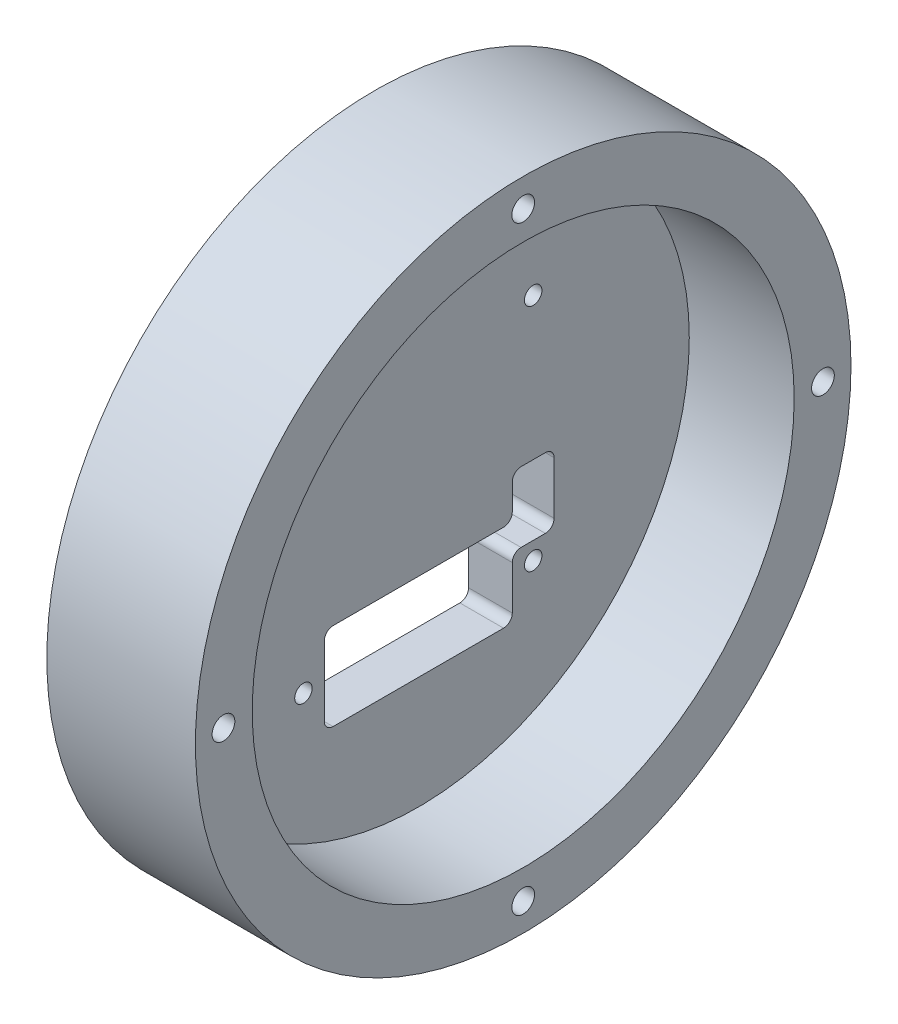
from build123d import *

# Parameters (mm, degrees)
SKETCH1_R               = 37.5
BOSS_EXTRUDE1_DEPTH     = 5
SKETCH3_R               = 1
CUT_EXTRUDE2_DEPTH      = 6
SKETCH4_R               = 37.5
SKETCH4_R_2             = 31
BOSS_EXTRUDE2_DEPTH     = 12
SKETCH2_R               = 1.3
CUT_EXTRUDE1_DEPTH      = 13
CUT_EXTRUDE1_DEPTH_BACK = 6
CUT_EXTRUDE3_DEPTH      = 6


with BuildPart() as part:
    # Sketch1 → Boss-Extrude1 (new body)
    with BuildSketch(Plane(origin=(0, 0, 0), x_dir=(0, 0, -1), z_dir=(1, 0, 0))):
        Circle(SKETCH1_R)
    extrude(amount=BOSS_EXTRUDE1_DEPTH)

    # Sketch3 → Cut-Extrude2 (cut, through all)
    with BuildSketch(Plane.ZY):
        with Locations((-13.14, 13.14)):
            Circle(SKETCH3_R)
        with Locations((13.14, 13.14)):
            Circle(SKETCH3_R)
        with Locations((13.14, -13.14)):
            Circle(SKETCH3_R)
        with Locations((-13.14, -13.14)):
            Circle(SKETCH3_R)
    extrude(amount=-CUT_EXTRUDE2_DEPTH, mode=Mode.SUBTRACT)

    # Sketch4 → Boss-Extrude2 (add)
    with BuildSketch(Plane(origin=(5, 0, 0), x_dir=(0, 0, -1), z_dir=(1, 0, 0))):
        Circle(SKETCH4_R)
        Circle(SKETCH4_R_2, mode=Mode.SUBTRACT)
    extrude(amount=BOSS_EXTRUDE2_DEPTH)

    # Sketch2 → Cut-Extrude1 (cut, two sides)
    with BuildSketch(Plane(origin=(5, 0, 0), x_dir=(0, 0, -1), z_dir=(1, 0, 0))) as cut_extrude1_sk:
        with Locations((0, 34.29)):
            Circle(SKETCH2_R)
        with Locations((34.29, 0)):
            Circle(SKETCH2_R)
        with Locations((0, -34.29)):
            Circle(SKETCH2_R)
        with Locations((-34.29, 0)):
            Circle(SKETCH2_R)
    extrude(amount=CUT_EXTRUDE1_DEPTH, mode=Mode.SUBTRACT)
    extrude(cut_extrude1_sk.sketch, amount=-CUT_EXTRUDE1_DEPTH_BACK, mode=Mode.SUBTRACT)

    # Sketch5 → Cut-Extrude3 (cut, through all)
    with BuildSketch(Plane(origin=(5, 0, 0), x_dir=(0, 0, -1), z_dir=(1, 0, 0))):
        with BuildLine():
            Line((9.75, -8.14), (-9.75, -8.14))
            ThreePointArc((-9.75, -8.14), (-10.457106781, -8.432893219), (-10.75, -9.14))
            Line((-10.75, -9.14), (-10.75, -17.14))
            ThreePointArc((-10.75, -17.14), (-10.457106781, -17.847106781), (-9.75, -18.14))
            Line((-9.75, -18.14), (9.75, -18.14))
            ThreePointArc((9.75, -18.14), (10.457106781, -17.847106781), (10.75, -17.14))
            Line((10.75, -17.14), (10.75, -12.14))
            ThreePointArc((10.75, -12.14), (11.042893219, -11.432893219), (11.75, -11.14))
            Line((11.75, -11.14), (14.53, -11.14))
            ThreePointArc((14.53, -11.14), (15.237106781, -10.847106781), (15.53, -10.14))
            Line((15.53, -10.14), (15.53, -4.14))
            ThreePointArc((15.53, -4.14), (15.237106781, -3.432893219), (14.53, -3.14))
            Line((14.53, -3.14), (11.75, -3.14))
            ThreePointArc((11.75, -3.14), (11.042893219, -3.432893219), (10.75, -4.14))
            Line((10.75, -4.14), (10.75, -7.14))
            ThreePointArc((10.75, -7.14), (10.457106781, -7.847106781), (9.75, -8.14))
        make_face()
    extrude(amount=-CUT_EXTRUDE3_DEPTH, mode=Mode.SUBTRACT)


solid = part.part
